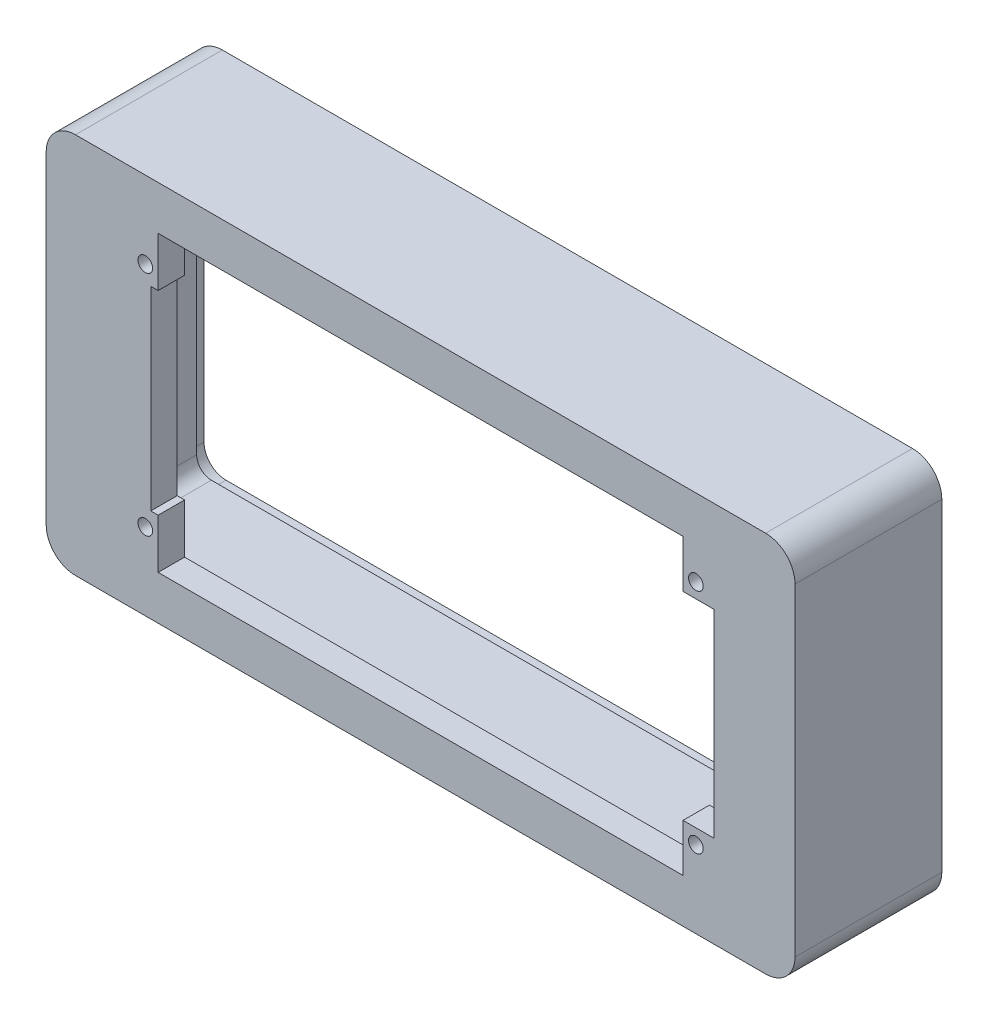
from build123d import *

# Parameters (mm, degrees)
ESQUISSE1_W                     = 102
ESQUISSE1_H                     = 52
ESQUISSE1_W_2                   = 90
ESQUISSE1_H_2                   = 40
EXTRU_MINCE1_DEPTH              = 3.6
ESQUISSE2_W                     = 9.25
ESQUISSE2_H                     = 40
BOSS_EXTRU_1_DEPTH              = 3.6
ESQUISSE3_R                     = 1
ESQUISSE3_W                     = 4.29767414
ESQUISSE3_H                     = 26.5
ENL_V_MAT_EXTRU_1_DEPTH         = 3.6
ESQUISSE5_W                     = 102
ESQUISSE5_H                     = 52
ESQUISSE5_W_2                   = 97
ESQUISSE5_H_2                   = 47
EXTRU_MINCE2_DEPTH              = 20
CONG_1_R                        = 4
CONG_2_R                        = 2
ENL_V_DE_MAT_EXTRU_MINCE1_DEPTH = 2


with BuildPart() as part:
    # Esquisse1 → Extru.-Mince1 (new body)
    with BuildSketch(Plane.XY):
        with Locations((45, 20)):
            Rectangle(ESQUISSE1_W, ESQUISSE1_H)
        with Locations((45, 20)):
            Rectangle(ESQUISSE1_W_2, ESQUISSE1_H_2, mode=Mode.SUBTRACT)
    extrude(amount=EXTRU_MINCE1_DEPTH)

    # Esquisse2 → Boss.-Extru.1 (add)
    with BuildSketch(Plane.XY):
        with Locations((4.625, 20)):
            Rectangle(ESQUISSE2_W, ESQUISSE2_H)
        Polygon((90, 40), (90, 0), (80.75, 0), (80.75, 6.5), (85, 6.5), (85, 33.5), (80.75, 33.5), (80.75, 40), align=None)
    extrude(amount=BOSS_EXTRU_1_DEPTH)

    # Esquisse3 → Enlèv. mat.-Extru.1 (cut)
    with BuildSketch(Plane.XY):
        with Locations((7.5, 35.5)):
            Circle(ESQUISSE3_R)
        with Locations((7.5, 4.5)):
            Circle(ESQUISSE3_R)
        with Locations((82.5, 35.5)):
            Circle(ESQUISSE3_R)
        with Locations((82.5, 4.5)):
            Circle(ESQUISSE3_R)
        with Locations((10.39883707, 20)):
            Rectangle(ESQUISSE3_W, ESQUISSE3_H)
    extrude(amount=ENL_V_MAT_EXTRU_1_DEPTH, mode=Mode.SUBTRACT)

    # Esquisse5 → Extru.-Mince2 (add)
    with BuildSketch(Plane.XY.offset(3.6)):
        with Locations((45, 20)):
            Rectangle(ESQUISSE5_W, ESQUISSE5_H)
        with Locations((45, 20)):
            Rectangle(ESQUISSE5_W_2, ESQUISSE5_H_2, mode=Mode.SUBTRACT)
    extrude(amount=-EXTRU_MINCE2_DEPTH)

    # Congé1
    cong_1_edges = [part.edges().sort_by_distance(p)[0] for p in [
        (-6, 46, -6.4),
        (96, 46, -6.4),
        (96, -6, -6.4),
        (-6, -6, -6.4),
    ]]
    fillet(cong_1_edges, radius=CONG_1_R)

    # Congé2
    cong_2_edges = [part.edges().sort_by_distance(p)[0] for p in [
        (45, -3.5, 0),
        (93.5, 20, 0),
        (93.5, -3.5, -8.2),
        (-3.5, -3.5, -8.2),
        (-3.5, 43.5, -8.2),
        (93.5, 43.5, -8.2),
        (45, 43.5, 0),
        (-3.5, 20, 0),
    ]]
    fillet(cong_2_edges, radius=CONG_2_R)

    # Esquisse6 → Enlèv. de mat.-Extru.-Mince1 (cut)
    with BuildSketch(Plane(origin=(0, 0, -16.4), x_dir=(-1, 0, 0), z_dir=(0, 0, -1))):
        with BuildLine():
            Line((1.5, 44.5), (-91.5, 44.5))
            ThreePointArc((-91.5, 44.5), (-93.621320344, 43.621320344), (-94.5, 41.5))
            Line((-94.5, 41.5), (-94.5, -1.5))
            ThreePointArc((-94.5, -1.5), (-93.621320344, -3.621320344), (-91.5, -4.5))
            Line((-91.5, -4.5), (1.5, -4.5))
            ThreePointArc((1.5, -4.5), (3.621320344, -3.621320344), (4.5, -1.5))
            Line((4.5, -1.5), (4.5, 41.5))
            ThreePointArc((4.5, 41.5), (3.621320344, 43.621320344), (1.5, 44.5))
        make_face()
        with BuildLine():
            Line((1.5, 43.5), (-91.5, 43.5))
            ThreePointArc((-91.5, 43.5), (-92.914213562, 42.914213562), (-93.5, 41.5))
            Line((-93.5, 41.5), (-93.5, -1.5))
            ThreePointArc((-93.5, -1.5), (-92.914213562, -2.914213562), (-91.5, -3.5))
            Line((-91.5, -3.5), (1.5, -3.5))
            ThreePointArc((1.5, -3.5), (2.914213562, -2.914213562), (3.5, -1.5))
            Line((3.5, -1.5), (3.5, 41.5))
            ThreePointArc((3.5, 41.5), (2.914213562, 42.914213562), (1.5, 43.5))
        make_face(mode=Mode.SUBTRACT)
    extrude(amount=-ENL_V_DE_MAT_EXTRU_MINCE1_DEPTH, mode=Mode.SUBTRACT)


solid = part.part
